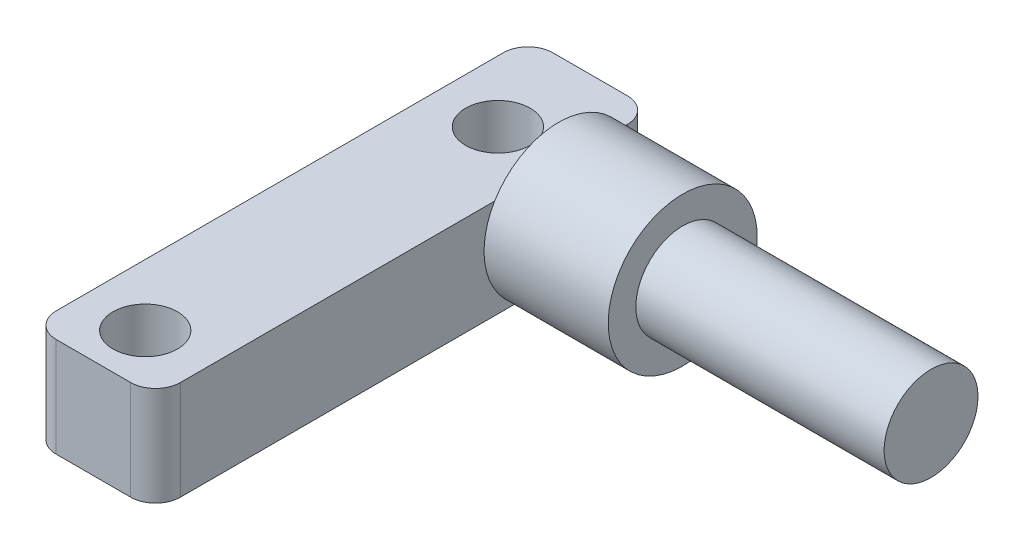
from build123d import *

# Parameters (mm, degrees)
SKETCH1_W           = 6.35
SKETCH1_H           = 25.4
EXTRUDE_THIN1_DEPTH = 5.08
FILLET4_R           = 1.27
FILLET5_R           = 1.27
FILLET6_R           = 1.27
SKETCH5_R           = 1.651
CUT_EXTRUDE1_DEPTH  = 6.35
SKETCH8_R           = 3.81
BOSS_EXTRUDE1_DEPTH = 6.35
SKETCH12_R          = 2.3999952
BOSS_EXTRUDE2_DEPTH = 19.05
LPATTERN1_COUNT     = 2
LPATTERN1_PITCH     = 18.034


with BuildPart() as part:
    # Sketch1 → Extrude-Thin1 (new body)
    with BuildSketch(Plane(origin=(0, 0, 0), x_dir=(1, 0, 0), z_dir=(0, 1, 0))):
        with Locations((-0.347720453, -19.952908818)):
            Rectangle(SKETCH1_W, SKETCH1_H)
    extrude(amount=EXTRUDE_THIN1_DEPTH)

    # Fillet4
    fillet4_edges = [part.edges().sort_by_distance(p)[0] for p in [
        (-3.522720453, 2.54, 32.652908818),
    ]]
    fillet(fillet4_edges, radius=FILLET4_R)

    # Fillet5
    fillet5_edges = [part.edges().sort_by_distance(p)[0] for p in [
        (2.827279547, 2.54, 32.652908818),
    ]]
    fillet(fillet5_edges, radius=FILLET5_R)

    # Fillet6
    fillet6_edges = [part.edges().sort_by_distance(p)[0] for p in [
        (-3.522720453, 2.54, 7.252908818),
        (2.827279547, 2.54, 7.252908818),
    ]]
    fillet(fillet6_edges, radius=FILLET6_R)

    # Sketch5 → Cut-Extrude1 (cut)
    with BuildSketch(Plane(origin=(0, 5.08, 0), x_dir=(1, 0, 0), z_dir=(0, 1, 0))):
        with Locations((-0.381, -29.972)):
            Circle(SKETCH5_R)
    cut_extrude1 = extrude(amount=-CUT_EXTRUDE1_DEPTH, mode=Mode.SUBTRACT)

    # Sketch8 → Boss-Extrude1 (add)
    with BuildSketch(Plane(origin=(2.827279547, 0, 0), x_dir=(0, 0, -1), z_dir=(1, 0, 0))):
        with Locations((-12.042526448, 3.1242)):
            Circle(SKETCH8_R)
    extrude(amount=BOSS_EXTRUDE1_DEPTH)

    # Sketch12 → Boss-Extrude2 (add)
    with BuildSketch(Plane(origin=(2.827279547, 0, 0), x_dir=(0, 0, -1), z_dir=(1, 0, 0))):
        with Locations((-12.042526448, 3.1242)):
            Circle(SKETCH12_R)
    extrude(amount=BOSS_EXTRUDE2_DEPTH)

    # LPattern1: Cut-Extrude1 ×2
    with Locations(*[(0, 0, -i * LPATTERN1_PITCH) for i in range(1, LPATTERN1_COUNT)]):
        add(cut_extrude1, mode=Mode.SUBTRACT)


solid = part.part
